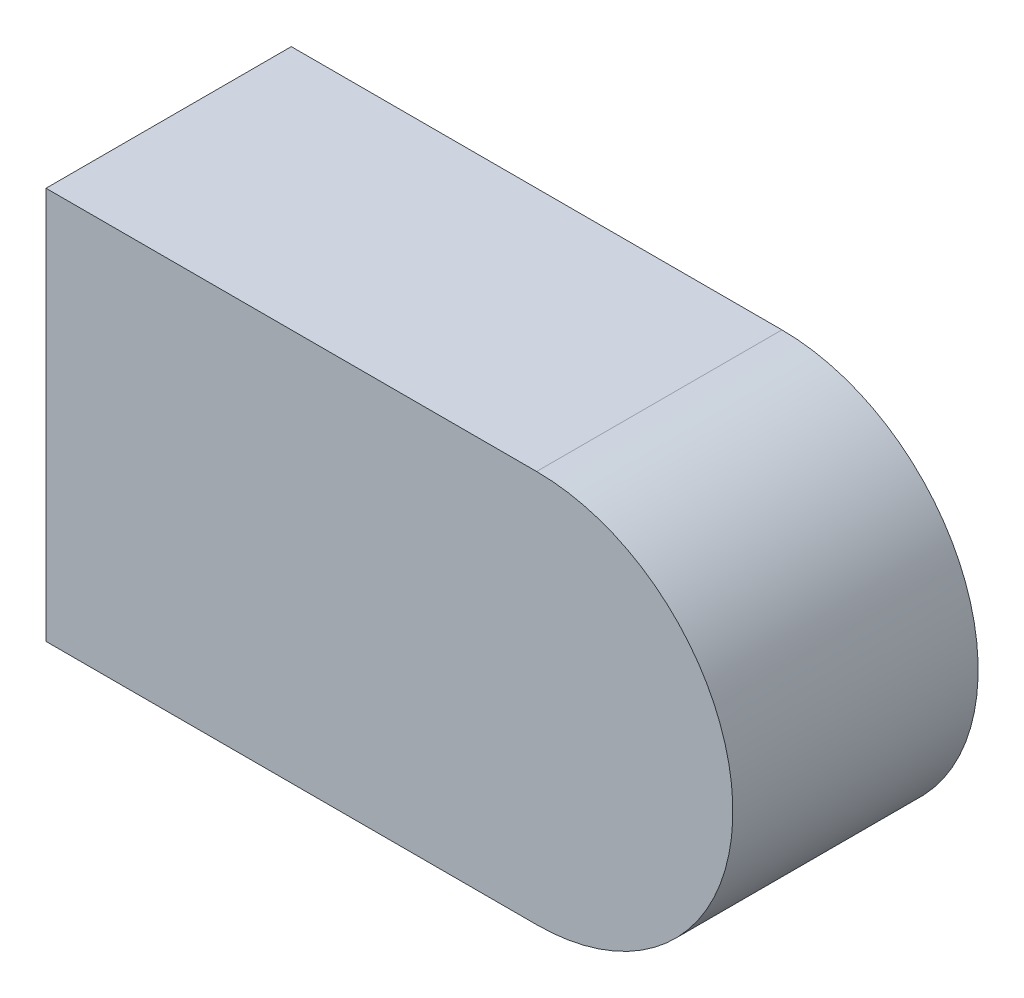
from build123d import *

# Parameters (mm, degrees)
BOSS_EXTRUDE1_DEPTH = 25


with BuildPart() as part:
    # Sketch1 → Boss-Extrude1 (new body)
    with BuildSketch(Plane.XY):
        with BuildLine():
            Line((-200, 232.5), (-250, 232.5))
            Line((-250, 232.5), (-250, 192.5))
            Line((-250, 192.5), (-200, 192.5))
            ThreePointArc((-200, 192.5), (-180, 212.5), (-200, 232.5))
        make_face()
    extrude(amount=-BOSS_EXTRUDE1_DEPTH)


solid = part.part
